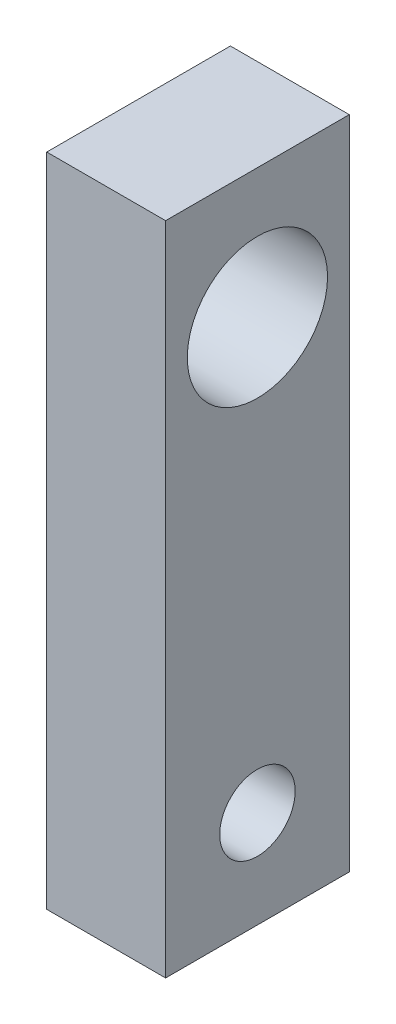
from build123d import *

# Parameters (mm, degrees)
SKETCH5_W           = 5.67
SKETCH5_H           = 20.25
SKETCH5_R           = 1.165
SKETCH5_R_2         = 2.165
BOSS_EXTRUDE2_DEPTH = 3.67


with BuildPart() as part:
    # Sketch5 → Boss-Extrude2 (new body)
    with BuildSketch(Plane(origin=(0, 0, 0), x_dir=(0, 0, -1), z_dir=(1, 0, 0))):
        with Locations((2.835, 10.125)):
            Rectangle(SKETCH5_W, SKETCH5_H)
        with Locations((2.835, 3)):
            Circle(SKETCH5_R, mode=Mode.SUBTRACT)
        with Locations((2.835, 16.25)):
            Circle(SKETCH5_R_2, mode=Mode.SUBTRACT)
    extrude(amount=BOSS_EXTRUDE2_DEPTH)


solid = part.part
